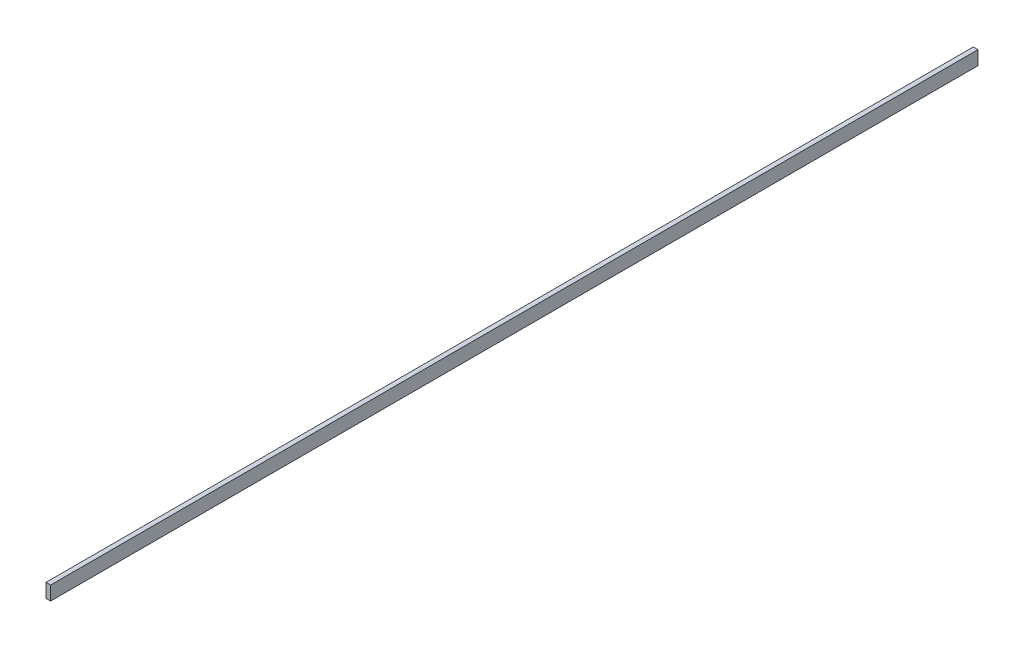
from build123d import *

# Parameters (mm, degrees)
ESBO_O1_W = 2
ESBO_O1_H = 6


with BuildPart() as part:
    # Varredura1: sweep along a path in Esboço2
    with BuildLine(Plane(origin=(0, 0, 0), x_dir=(1, 0, 0), z_dir=(0, 1, 0))) as varredura1_path:
        Line((0, 0), (0, 400))
    # Esboço1 → Varredura1 (sweep)
    with BuildSketch(Plane.XY):
        Rectangle(ESBO_O1_W, ESBO_O1_H)
    sweep(path=varredura1_path.line)


solid = part.part
